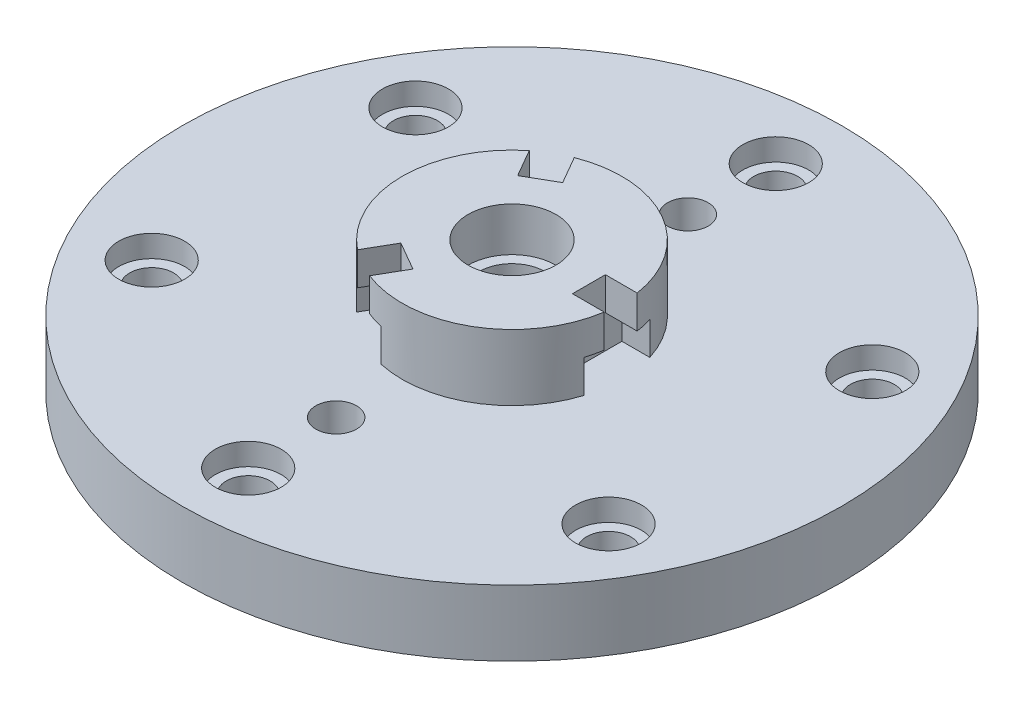
from build123d import *

# Parameters (mm, degrees)
SKETCH4_W                               = 38.383060538
SKETCH4_H                               = 30
CUT_EXTRUDE1_DEPTH                      = 15
SKETCH5_W                               = 44.391966134
SKETCH5_H                               = 15
CUT_EXTRUDE2_DEPTH                      = 31
CBORE_FOR_M5_HEX_HEAD_BOLT1_D           = 20
CBORE_FOR_M5_HEX_HEAD_BOLT1_CBORE_D     = 30
CBORE_FOR_M5_HEX_HEAD_BOLT1_CBORE_DEPTH = 10
CIRPATTERN1_COUNT                       = 6
TAP_DRILL_FOR_M20X1_5_TAP1_D            = 18.5
CIRPATTERN2_COUNT                       = 2
CUT_EXTRUDE4_DEPTH                      = 30
FILLET1_R                               = 5
FILLET2_R                               = 10
SKETCH13_R                              = 8
CUT_EXTRUDE5_DEPTH                      = 126


with BuildPart() as part:
    # Sketch2 → Revolve1 (revolve)
    with BuildSketch(Plane.XY):
        Polygon((-20, 130), (-20, 110), (-15, 110), (-15, 0), (-30, 0), (-30, 50), (-60, 50), (-60, 70), (-150, 70), (-150, 100), (-50, 100), (-50, 130), align=None)
    revolve(axis=Axis((0, 0, 0), (0, 1, 0)))

    # Sketch4 → Cut-Extrude1 (cut)
    with BuildSketch(Plane(origin=(0, 100, 0), x_dir=(1, 0, 0), z_dir=(0, 1, 0))):
        Polygon((-49.681911326, -56.051594634), (-23.701149212, -71.051594634), (-4.509618943, -37.810889132), (-30.490381057, -22.810889132), align=None)
        with Locations((54.191530269, 0)):
            Rectangle(SKETCH4_W, SKETCH4_H)
        Polygon((-23.701149212, 71.051594634), (-49.681911326, 56.051594634), (-30.490381057, 22.810889132), (-4.509618943, 37.810889132), align=None)
    extrude(amount=CUT_EXTRUDE1_DEPTH, mode=Mode.SUBTRACT)

    # Sketch5 → Cut-Extrude2 (cut, through all)
    with BuildSketch(Plane(origin=(0, 100, 0), x_dir=(1, 0, 0), z_dir=(0, 1, 0))):
        Polygon((-46.191173595, -65.005459528), (-33.200792538, -72.505459528), (-11.004809472, -34.060889132), (-23.995190528, -26.560889132), align=None)
        with Locations((57.195983067, 0)):
            Rectangle(SKETCH5_W, SKETCH5_H)
        Polygon((-33.200792538, 72.505459528), (-46.191173595, 65.005459528), (-23.995190528, 26.560889132), (-11.004809472, 34.060889132), align=None)
    extrude(amount=CUT_EXTRUDE2_DEPTH, mode=Mode.SUBTRACT)

    # CBORE for M5 Hex Head Bolt1 (through all)
    with Locations(Plane(origin=(0, 100, 0), x_dir=(1, 0, 0), z_dir=(0, 1, 0))):
        with Locations((0, 120)):
            cbore_for_m5_hex_head_bolt1 = CounterBoreHole(CBORE_FOR_M5_HEX_HEAD_BOLT1_D / 2, CBORE_FOR_M5_HEX_HEAD_BOLT1_CBORE_D / 2, CBORE_FOR_M5_HEX_HEAD_BOLT1_CBORE_DEPTH)

    # CirPattern1: CBORE for M5 Hex Head Bolt1 ×6 about axis
    cirpattern1_axis = Axis((0, 0, 0), (0, 1, 0))
    for i in range(1, CIRPATTERN1_COUNT):
        add(cbore_for_m5_hex_head_bolt1.rotate(cirpattern1_axis, i * 360 / CIRPATTERN1_COUNT), mode=Mode.SUBTRACT)

    # Tap Drill for M20x1.5 Tap1 (through all)
    with Locations(Plane(origin=(0, 100, 0), x_dir=(1, 0, 0), z_dir=(0, 1, 0))):
        with Locations((0, 80)):
            tap_drill_for_m20x1_5_tap1 = Hole(TAP_DRILL_FOR_M20X1_5_TAP1_D / 2)

    # CirPattern2: Tap Drill for M20x1.5 Tap1 ×2 about axis
    cirpattern2_axis = Axis((0, 0, 0), (0, 1, 0))
    for i in range(1, CIRPATTERN2_COUNT):
        add(tap_drill_for_m20x1_5_tap1.rotate(cirpattern2_axis, i * 360 / CIRPATTERN2_COUNT), mode=Mode.SUBTRACT)

    # Sketch12 → Cut-Extrude4 (cut)
    with BuildSketch(Plane.XZ):
        with BuildLine():
            Line((-28.91366459, -8), (-25, -8))
            Line((-25, -8), (-25, 8))
            Line((-25, 8), (-28.91366459, 8))
            ThreePointArc((-28.91366459, 8), (-30, 0), (-28.91366459, -8))
        make_face()
        with BuildLine():
            Line((25, 8), (25, -8))
            Line((25, -8), (28.91366459, -8))
            ThreePointArc((28.91366459, -8), (30, 0), (28.91366459, 8))
            Line((28.91366459, 8), (25, 8))
        make_face()
    extrude(amount=-CUT_EXTRUDE4_DEPTH, mode=Mode.SUBTRACT)

    # Fillet1
    fillet1_edges = [part.edges().sort_by_distance(p)[0] for p in [
        (60, 70, 0),
        (60, 50, 0),
    ]]
    fillet(fillet1_edges, radius=FILLET1_R)

    # Fillet2
    fillet2_edges = [part.edges().sort_by_distance(p)[0] for p in [
        (30, 50, 0),
    ]]
    fillet(fillet2_edges, radius=FILLET2_R)

    # Sketch13 → Cut-Extrude5 (cut, through all)
    with BuildSketch(Plane(origin=(25, 0, 0), x_dir=(0, 0, -1), z_dir=(1, 0, 0))):
        with Locations((0, 30)):
            Circle(SKETCH13_R)
    cut_extrude5 = extrude(amount=CUT_EXTRUDE5_DEPTH, mode=Mode.SUBTRACT)

    # Mirror1: Cut-Extrude5 across plane
    add(cut_extrude5.mirror(Plane(origin=(0, 0, 0), x_dir=(0, 0, 1), z_dir=(1, 0, 0))), mode=Mode.SUBTRACT)


solid = part.part
